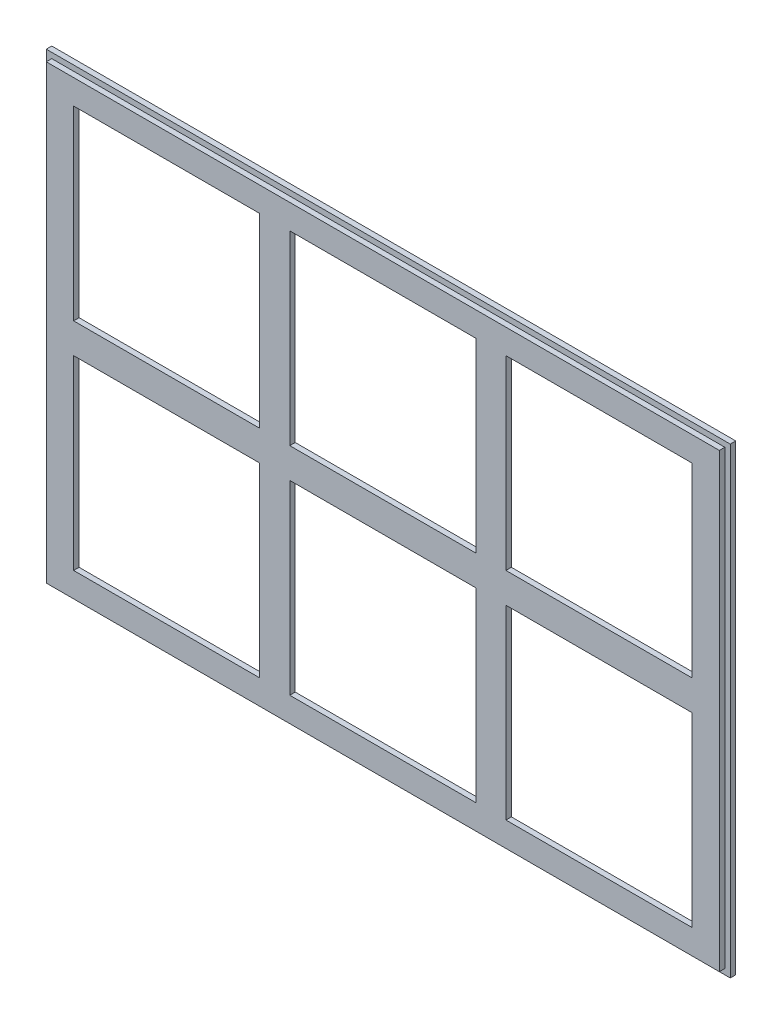
from build123d import *

# Parameters (mm, degrees)
SKETCH1_W           = 1250
SKETCH1_H           = 845
BOSS_EXTRUDE1_DEPTH = 20
SKETCH2_W           = 360
SKETCH2_H           = 360
CUT_EXTRUDE1_DEPTH  = 10
SKETCH3_W           = 340
SKETCH3_H           = 340
CUT_EXTRUDE2_DEPTH  = 11
SKETCH4_W           = 1250
SKETCH4_H           = 845
SKETCH4_W_2         = 1230
SKETCH4_H_2         = 825
CUT_EXTRUDE3_DEPTH  = 10


with BuildPart() as part:
    # Sketch1 → Boss-Extrude1 (new body)
    with BuildSketch(Plane.XY):
        Rectangle(SKETCH1_W, SKETCH1_H)
    extrude(amount=BOSS_EXTRUDE1_DEPTH)

    # Sketch2 → Cut-Extrude1 (cut)
    with BuildSketch(Plane(origin=(0, 0, 0), x_dir=(-1, 0, 0), z_dir=(0, 0, -1))):
        with Locations((-395, 197.5)):
            Rectangle(SKETCH2_W, SKETCH2_H)
        with BuildLine():
            Line((-575, 372.627718677), (-575, 377.5))
            Line((-575, 377.5), (-570.127718677, 377.5))
            ThreePointArc((-570.127718677, 377.5), (-575.474873734, 377.974873734), (-575, 372.627718677))
        make_face()
        with BuildLine():
            ThreePointArc((-215, 372.627718677), (-214.525126266, 377.974873734), (-219.872281323, 377.5))
            Line((-219.872281323, 377.5), (-215, 377.5))
            Line((-215, 377.5), (-215, 372.627718677))
        make_face()
        with BuildLine():
            Line((-180, 372.627718677), (-180, 377.5))
            Line((-180, 377.5), (-175.127718677, 377.5))
            ThreePointArc((-175.127718677, 377.5), (-180.474873734, 377.974873734), (-180, 372.627718677))
        make_face()
        with BuildLine():
            Line((-575, 17.5), (-575, 22.372281323))
            ThreePointArc((-575, 22.372281323), (-575.474873734, 17.025126266), (-570.127718677, 17.5))
            Line((-570.127718677, 17.5), (-575, 17.5))
        make_face()
        with BuildLine():
            ThreePointArc((-219.872281323, 17.5), (-214.525126266, 17.025126266), (-215, 22.372281323))
            Line((-215, 22.372281323), (-215, 17.5))
            Line((-215, 17.5), (-219.872281323, 17.5))
        make_face()
        with BuildLine():
            Line((-180, 17.5), (-180, 22.372281323))
            ThreePointArc((-180, 22.372281323), (-180.474873734, 17.025126266), (-175.127718677, 17.5))
            Line((-175.127718677, 17.5), (-180, 17.5))
        make_face()
        with Locations((0, 197.5)):
            Rectangle(SKETCH2_W, SKETCH2_H)
        with BuildLine():
            Line((180, 17.5), (175.127718677, 17.5))
            ThreePointArc((175.127718677, 17.5), (180.474873734, 17.025126266), (180, 22.372281323))
            Line((180, 22.372281323), (180, 17.5))
        make_face()
        with BuildLine():
            Line((175.127718677, -17.5), (180, -17.5))
            Line((180, -17.5), (180, -22.372281323))
            ThreePointArc((180, -22.372281323), (180.474873734, -17.025126266), (175.127718677, -17.5))
        make_face()
        with BuildLine():
            Line((215, -17.5), (219.872281323, -17.5))
            ThreePointArc((219.872281323, -17.5), (214.525126266, -17.025126266), (215, -22.372281323))
            Line((215, -22.372281323), (215, -17.5))
        make_face()
        with BuildLine():
            Line((215, 17.5), (215, 22.372281323))
            ThreePointArc((215, 22.372281323), (214.525126266, 17.025126266), (219.872281323, 17.5))
            Line((219.872281323, 17.5), (215, 17.5))
        make_face()
        with Locations((395, 197.5)):
            Rectangle(SKETCH2_W, SKETCH2_H)
        with BuildLine():
            ThreePointArc((180, 372.627718677), (180.474873734, 377.974873734), (175.127718677, 377.5))
            Line((175.127718677, 377.5), (180, 377.5))
            Line((180, 377.5), (180, 372.627718677))
        make_face()
        with BuildLine():
            Line((215, 372.627718677), (215, 377.5))
            Line((215, 377.5), (219.872281323, 377.5))
            ThreePointArc((219.872281323, 377.5), (214.525126266, 377.974873734), (215, 372.627718677))
        make_face()
        with BuildLine():
            ThreePointArc((575, 372.627718677), (575.474873734, 377.974873734), (570.127718677, 377.5))
            Line((570.127718677, 377.5), (575, 377.5))
            Line((575, 377.5), (575, 372.627718677))
        make_face()
        with BuildLine():
            Line((575, 17.5), (570.127718677, 17.5))
            ThreePointArc((570.127718677, 17.5), (575.474873734, 17.025126266), (575, 22.372281323))
            Line((575, 22.372281323), (575, 17.5))
        make_face()
        with BuildLine():
            Line((570.127718677, -17.5), (575, -17.5))
            Line((575, -17.5), (575, -22.372281323))
            ThreePointArc((575, -22.372281323), (575.474873734, -17.025126266), (570.127718677, -17.5))
        make_face()
        with Locations((395, -197.5)):
            Rectangle(SKETCH2_W, SKETCH2_H)
        with BuildLine():
            ThreePointArc((570.127718677, -377.5), (575.474873734, -377.974873734), (575, -372.627718677))
            Line((575, -372.627718677), (575, -377.5))
            Line((575, -377.5), (570.127718677, -377.5))
        make_face()
        with BuildLine():
            Line((215, -377.5), (215, -372.627718677))
            ThreePointArc((215, -372.627718677), (214.525126266, -377.974873734), (219.872281323, -377.5))
            Line((219.872281323, -377.5), (215, -377.5))
        make_face()
        with BuildLine():
            ThreePointArc((175.127718677, -377.5), (180.474873734, -377.974873734), (180, -372.627718677))
            Line((180, -372.627718677), (180, -377.5))
            Line((180, -377.5), (175.127718677, -377.5))
        make_face()
        with Locations((0, -197.5)):
            Rectangle(SKETCH2_W, SKETCH2_H)
        with BuildLine():
            Line((-180, -17.5), (-175.127718677, -17.5))
            ThreePointArc((-175.127718677, -17.5), (-180.474873734, -17.025126266), (-180, -22.372281323))
            Line((-180, -22.372281323), (-180, -17.5))
        make_face()
        with BuildLine():
            Line((-215, -17.5), (-215, -22.372281323))
            ThreePointArc((-215, -22.372281323), (-214.525126266, -17.025126266), (-219.872281323, -17.5))
            Line((-219.872281323, -17.5), (-215, -17.5))
        make_face()
        with Locations((-395, -197.5)):
            Rectangle(SKETCH2_W, SKETCH2_H)
        with BuildLine():
            ThreePointArc((-570.127718677, -17.5), (-575.474873734, -17.025126266), (-575, -22.372281323))
            Line((-575, -22.372281323), (-575, -17.5))
            Line((-575, -17.5), (-570.127718677, -17.5))
        make_face()
        with BuildLine():
            ThreePointArc((-575, -372.627718677), (-575.474873734, -377.974873734), (-570.127718677, -377.5))
            Line((-570.127718677, -377.5), (-575, -377.5))
            Line((-575, -377.5), (-575, -372.627718677))
        make_face()
        with BuildLine():
            Line((-215, -372.627718677), (-215, -377.5))
            Line((-215, -377.5), (-219.872281323, -377.5))
            ThreePointArc((-219.872281323, -377.5), (-214.525126266, -377.974873734), (-215, -372.627718677))
        make_face()
        with BuildLine():
            ThreePointArc((-180, -372.627718677), (-180.474873734, -377.974873734), (-175.127718677, -377.5))
            Line((-175.127718677, -377.5), (-180, -377.5))
            Line((-180, -377.5), (-180, -372.627718677))
        make_face()
    extrude(amount=-CUT_EXTRUDE1_DEPTH, mode=Mode.SUBTRACT)

    # Sketch3 → Cut-Extrude2 (cut, through all)
    with BuildSketch(Plane(origin=(0, 0, 10), x_dir=(-1, 0, 0), z_dir=(0, 0, -1))):
        with Locations((0, 197.5)):
            Rectangle(SKETCH3_W, SKETCH3_H)
        with Locations((395, 197.5)):
            Rectangle(SKETCH3_W, SKETCH3_H)
        with Locations((-395, 197.5)):
            Rectangle(SKETCH3_W, SKETCH3_H)
        with Locations((-395, -197.5)):
            Rectangle(SKETCH3_W, SKETCH3_H)
        with Locations((0, -197.5)):
            Rectangle(SKETCH3_W, SKETCH3_H)
        with Locations((395, -197.5)):
            Rectangle(SKETCH3_W, SKETCH3_H)
    extrude(amount=-CUT_EXTRUDE2_DEPTH, mode=Mode.SUBTRACT)

    # Sketch4 → Cut-Extrude3 (cut)
    with BuildSketch(Plane.XY.offset(20)):
        Rectangle(SKETCH4_W, SKETCH4_H)
        Rectangle(SKETCH4_W_2, SKETCH4_H_2, mode=Mode.SUBTRACT)
    extrude(amount=-CUT_EXTRUDE3_DEPTH, mode=Mode.SUBTRACT)


solid = part.part
